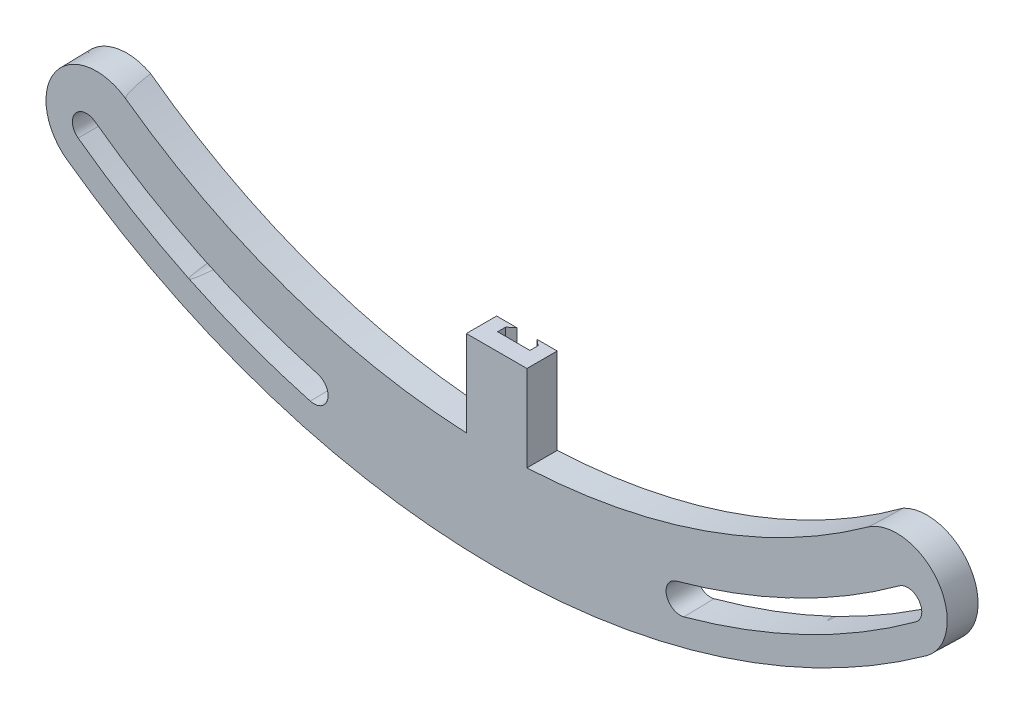
from build123d import *

# Parameters (mm, degrees)
SKETCH1_W           = 3.81
SKETCH1_H           = 12.7
SKETCH2_R           = 1.778
CUT_EXTRUDE1_DEPTH  = 4.81
SKETCH3_OUTSIDE_W   = 239.386
SKETCH3_OUTSIDE_H   = 239.386
CUT_EXTRUDE15_DEPTH = 4.81
CUT_EXTRUDE15_TAPER = 1
SKETCH8_W           = 7.62
SKETCH8_H           = 3.81
BOSS_EXTRUDE1_DEPTH = 10.922
CUT_EXTRUDE16_DEPTH = 6.096


with BuildPart() as part:
    # Sketch1 → Revolve1 (revolve)
    with BuildSketch(Plane(origin=(0, 0, 0), x_dir=(0, 0, -1), z_dir=(1, 0, 0)), mode=Mode.PRIVATE) as revolve1_sk:
        with Locations((-1.905, 86.106)):
            Rectangle(SKETCH1_W, SKETCH1_H)
    revolve(revolve1_sk.sketch.rotate(Axis((0, 0, 0), (0, 0, -1)), 90), axis=Axis((0, 0, 0), (0, 0, -1)))  # turned: the seam where the file's is

    # Sketch2 → Cut-Extrude1 (cut, through all)
    with BuildSketch(Plane.XY.offset(3.81)):
        with Locations((0, 87.376)):
            Circle(SKETCH2_R)
        with Locations((68.313308, 54.478045)):
            Circle(SKETCH2_R)
        with Locations((85.185301, -19.442989)):
            Circle(SKETCH2_R)
        with Locations((37.911026, -78.723056)):
            Circle(SKETCH2_R)
        with Locations((-37.911026, -78.723056)):
            Circle(SKETCH2_R)
        with Locations((-85.185301, -19.442989)):
            Circle(SKETCH2_R)
        with Locations((-68.313308, 54.478045)):
            Circle(SKETCH2_R)
    extrude(amount=-CUT_EXTRUDE1_DEPTH, mode=Mode.SUBTRACT)

    # Sketch3 outside → Cut-Extrude15 (cut, through all)
    with BuildSketch(Plane.XY.offset(3.81)):
        Rectangle(SKETCH3_OUTSIDE_W, SKETCH3_OUTSIDE_H)
        with BuildLine():
            ThreePointArc((-46.620921, -64.710967), (-55.484924, -66.151258), (-54.044634, -75.015262))
            ThreePointArc((-54.044634, -75.015262), (0, -92.456), (54.044634, -75.015262))
            ThreePointArc((54.044634, -75.015262), (55.484924, -66.151258), (46.620921, -64.710967))
            ThreePointArc((46.620921, -64.710967), (0, -79.756), (-46.620921, -64.710967))
        make_face(mode=Mode.SUBTRACT)
        with BuildLine():
            ThreePointArc((-52.63259, -71.960032), (-38.682471, -80.324978), (-23.444735, -86.016162))
            ThreePointArc((-23.444735, -86.016162), (-21.261754, -84.768299), (-22.509617, -82.585318))
            ThreePointArc((-22.509617, -82.585318), (-37.13958, -77.121133), (-50.533285, -69.089831))
            ThreePointArc((-50.533285, -69.089831), (-53.018038, -69.475278), (-52.63259, -71.960032))
        make_face()
        with BuildLine():
            ThreePointArc((23.563518, -86.016162), (38.801254, -80.324978), (52.751374, -71.960032))
            ThreePointArc((52.751374, -71.960032), (53.136821, -69.475278), (50.652068, -69.089831))
            ThreePointArc((50.652068, -69.089831), (37.258363, -77.121133), (22.6284, -82.585318))
            ThreePointArc((22.6284, -82.585318), (21.380537, -84.768299), (23.563518, -86.016162))
        make_face()
    extrude(amount=-CUT_EXTRUDE15_DEPTH, taper=CUT_EXTRUDE15_TAPER, mode=Mode.SUBTRACT)

    # Sketch8 → Boss-Extrude1 (add)
    with BuildSketch(Plane.XZ.offset(79.756)):
        with Locations((0, 1.905)):
            Rectangle(SKETCH8_W, SKETCH8_H)
    extrude(amount=-BOSS_EXTRUDE1_DEPTH)

    # Sketch9 → Cut-Extrude16 (cut)
    with BuildSketch(Plane(origin=(0, -68.834, 0), x_dir=(1, 0, 0), z_dir=(0, 1, 0))):
        Polygon((1.27, 0), (-1.27, 0), (-2.032, -0.635), (-2.032, -1.651), (2.032, -1.651), (2.032, -0.635), align=None)
    extrude(amount=-CUT_EXTRUDE16_DEPTH, mode=Mode.SUBTRACT)


solid = part.part
